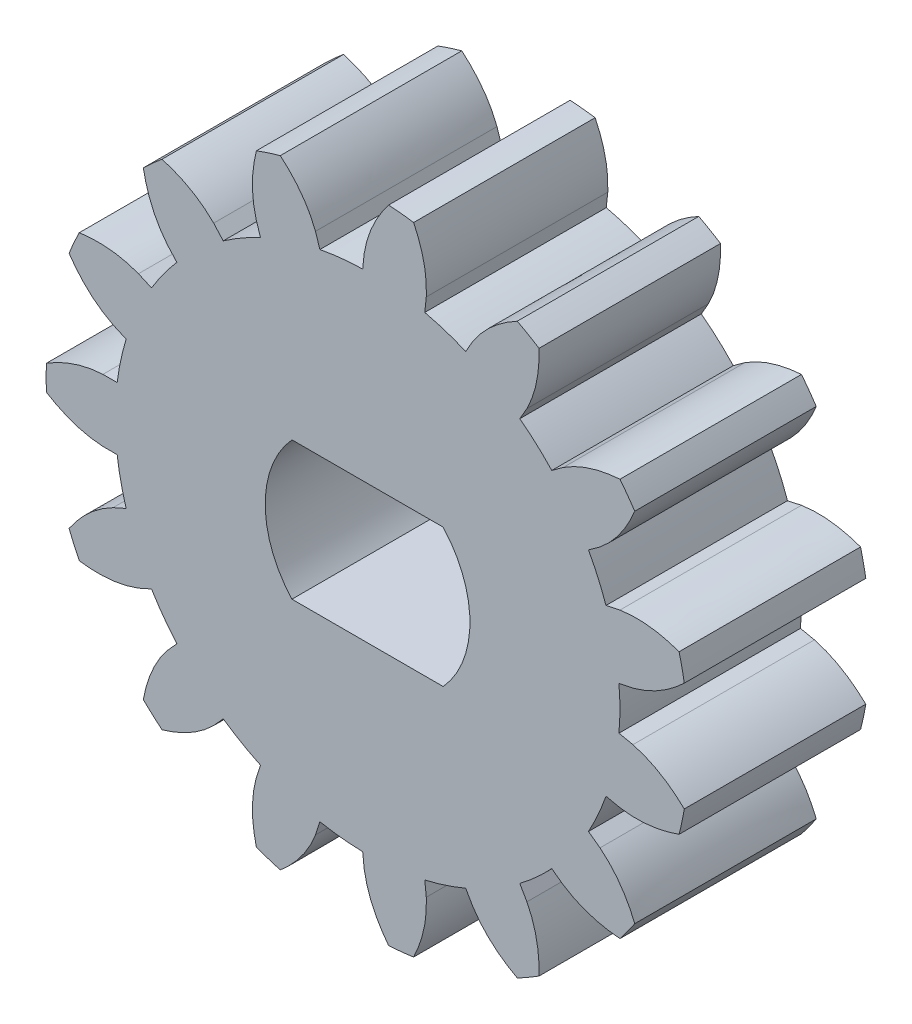
from build123d import *

# Parameters (mm, degrees)
SKETCH12_R         = 6.673371428
CORE_CYL_DEPTH     = 4.8
TOOTH_EX_DEPTH     = 4.8
CIRPATTERN1_COUNT  = 15
SKETCH13_W         = 4
SKETCH13_H         = 3.65
CUT_EXTRUDE1_DEPTH = 4


with BuildPart() as part:
    # Sketch12 → core_cyl (new body)
    with BuildSketch(Plane.XY):
        Circle(SKETCH12_R)
    extrude(amount=CORE_CYL_DEPTH)

    # tooth → tooth_ex (add)
    with BuildSketch(Plane.XY):
        with BuildLine():
            add(Edge.make_bspline(
                [(-0.089470773, 7.047126715), (-0.005108471, 7.588530401), (0.233889853, 8.063511638), (0.55714541, 8.481720874)],
                knots=[0, 0, 0, 0, 0.44996315, 0.44996315, 0.44996315, 0.44996315], degree=3))
            Line((-0.089470773, 7.047126715), (-0.128884861, 6.672126715))
            ThreePointArc((-0.128884861, 6.672126715), (0.69755726, 6.636814001), (1.513281564, 6.499528069))
            Line((1.513281564, 6.499528069), (1.552695653, 6.874528069))
            add(Edge.make_bspline(
                [(1.552695653, 6.874528069), (1.582741025, 7.421640695), (1.44771954, 7.935932997), (1.218478482, 8.412211968)],
                knots=[0, 0, 0, 0, 0.44996315, 0.44996315, 0.44996315, 0.44996315], degree=3))
            ThreePointArc((1.218478482, 8.412211968), (0.888491938, 8.453436111), (0.55714541, 8.481720874))
        make_face()
    tooth_ex = extrude(amount=TOOTH_EX_DEPTH)

    # CirPattern1: tooth_ex ×15 about axis
    cirpattern1_axis = Axis((0, 0, 0), (0, 0, 1))
    for i in range(1, CIRPATTERN1_COUNT):
        add(tooth_ex.rotate(cirpattern1_axis, i * 360 / CIRPATTERN1_COUNT))

    # Sketch13 → Cut-Extrude1 (cut)
    with BuildSketch(Plane.XY.offset(4.8)):
        with BuildLine():
            Line((-2, -1.825), (-2, 1.825))
            ThreePointArc((-2, 1.825), (-2.707512696, 0), (-2, -1.825))
        make_face()
        Rectangle(SKETCH13_W, SKETCH13_H)
        with BuildLine():
            ThreePointArc((2.707512696, 0), (2.524445523, 0.97867247), (2, 1.825))
            Line((2, 1.825), (2, -1.825))
            ThreePointArc((2, -1.825), (2.524445523, -0.97867247), (2.707512696, 0))
        make_face()
    extrude(amount=-CUT_EXTRUDE1_DEPTH, mode=Mode.SUBTRACT)


solid = part.part
